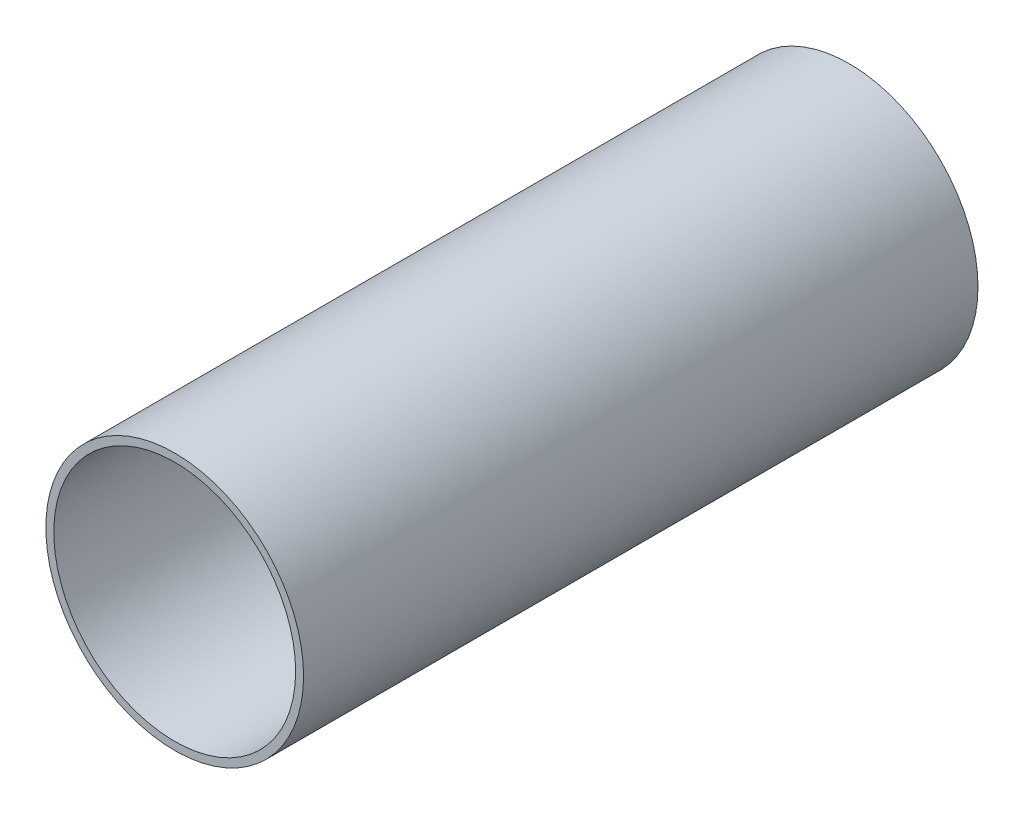
from build123d import *

# Parameters (mm, degrees)
SKETCH1_R           = 162.4
SKETCH1_R_2         = 152.4
EXTRUDE_THIN1_DEPTH = 850


with BuildPart() as part:
    # Sketch1 → Extrude-Thin1 (new body)
    with BuildSketch(Plane.XY):
        with Locations((2240, 0)):
            Circle(SKETCH1_R)
        with Locations((2240, 0)):
            Circle(SKETCH1_R_2, mode=Mode.SUBTRACT)
    extrude(amount=EXTRUDE_THIN1_DEPTH)


solid = part.part
